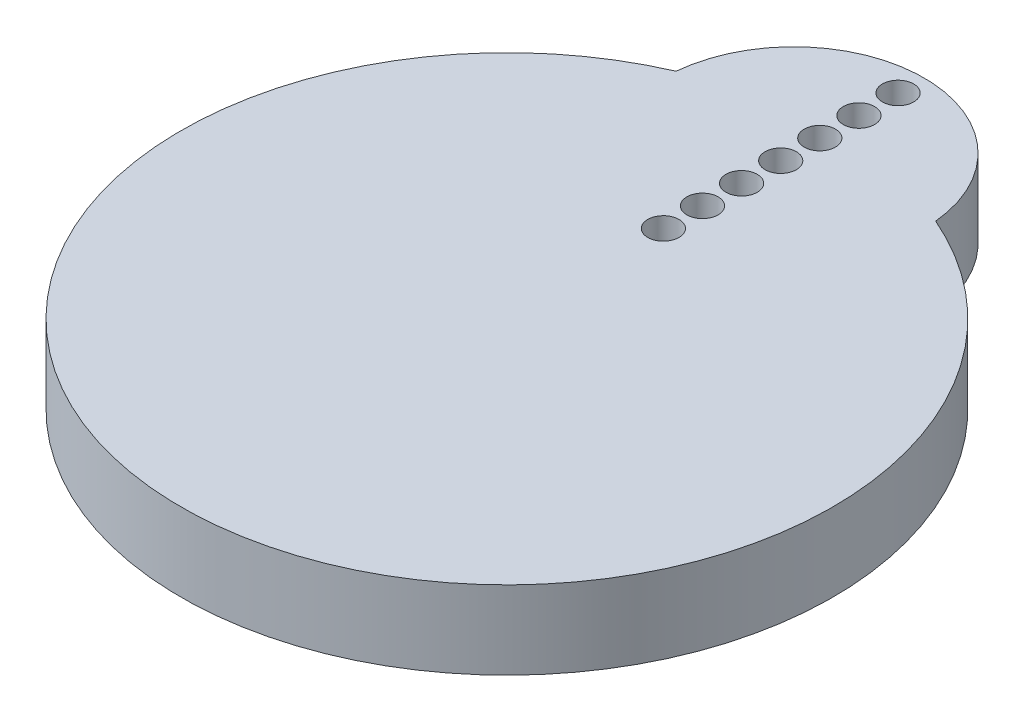
from build123d import *

# Parameters (mm, degrees)
SKETCH1_R           = 12.5
BOSS_EXTRUDE1_DEPTH = 3
SKETCH3_R           = 5
BOSS_EXTRUDE2_DEPTH = 3
CUT_EXTRUDE1_DEPTH  = 10


with BuildPart() as part:
    # Sketch1 → Boss-Extrude1 (new body)
    with BuildSketch(Plane(origin=(0, 0, 0), x_dir=(1, 0, 0), z_dir=(0, 1, 0))):
        Circle(SKETCH1_R)
    extrude(amount=BOSS_EXTRUDE1_DEPTH)

    # Sketch3 → Boss-Extrude2 (add)
    with BuildSketch(Plane(origin=(0, 3, 0), x_dir=(1, 0, 0), z_dir=(0, 1, 0))):
        with Locations((0, 11)):
            Circle(SKETCH3_R)
    extrude(amount=-BOSS_EXTRUDE2_DEPTH)

    # Sketch4 → Cut-Extrude1 (cut)
    with BuildSketch(Plane(origin=(0, 3, 0), x_dir=(1, 0, 0), z_dir=(0, 1, 0))):
        with BuildLine():
            ThreePointArc((0.6, 6), (0.424264069, 6.424264069), (0, 6.6))
            Line((0, 6.6), (0, 5.4))
            ThreePointArc((0, 5.4), (0.424264069, 5.575735931), (0.6, 6))
        make_face()
        with BuildLine():
            Line((0, 5.4), (0, 6.6))
            ThreePointArc((0, 6.6), (-0.6, 6), (0, 5.4))
        make_face()
        with BuildLine():
            ThreePointArc((0.6, 7.5), (0.424264069, 7.924264069), (0, 8.1))
            Line((0, 8.1), (0, 6.9))
            ThreePointArc((0, 6.9), (0.424264069, 7.075735931), (0.6, 7.5))
        make_face()
        with BuildLine():
            Line((0, 6.9), (0, 8.1))
            ThreePointArc((0, 8.1), (-0.6, 7.5), (0, 6.9))
        make_face()
        with BuildLine():
            ThreePointArc((0.6, 9), (0.424264069, 9.424264069), (0, 9.6))
            Line((0, 9.6), (0, 8.4))
            ThreePointArc((0, 8.4), (0.424264069, 8.575735931), (0.6, 9))
        make_face()
        with BuildLine():
            Line((0, 8.4), (0, 9.6))
            ThreePointArc((0, 9.6), (-0.6, 9), (0, 8.4))
        make_face()
        with BuildLine():
            ThreePointArc((0.6, 10.5), (0.424264069, 10.924264069), (0, 11.1))
            Line((0, 11.1), (0, 9.9))
            ThreePointArc((0, 9.9), (0.424264069, 10.075735931), (0.6, 10.5))
        make_face()
        with BuildLine():
            Line((0, 9.9), (0, 11.1))
            ThreePointArc((0, 11.1), (-0.6, 10.5), (0, 9.9))
        make_face()
        with BuildLine():
            ThreePointArc((0.6, 12), (0.424264069, 12.424264069), (0, 12.6))
            Line((0, 12.6), (0, 11.4))
            ThreePointArc((0, 11.4), (0.424264069, 11.575735931), (0.6, 12))
        make_face()
        with BuildLine():
            Line((0, 11.4), (0, 12.6))
            ThreePointArc((0, 12.6), (-0.6, 12), (0, 11.4))
        make_face()
        with BuildLine():
            ThreePointArc((0.6, 13.5), (0.424264069, 13.924264069), (0, 14.1))
            Line((0, 14.1), (0, 12.9))
            ThreePointArc((0, 12.9), (0.424264069, 13.075735931), (0.6, 13.5))
        make_face()
        with BuildLine():
            Line((0, 12.9), (0, 14.1))
            ThreePointArc((0, 14.1), (-0.6, 13.5), (0, 12.9))
        make_face()
        with BuildLine():
            ThreePointArc((0.6, 15), (0.424264069, 15.424264069), (0, 15.6))
            Line((0, 15.6), (0, 14.4))
            ThreePointArc((0, 14.4), (0.424264069, 14.575735931), (0.6, 15))
        make_face()
        with BuildLine():
            Line((0, 14.4), (0, 15.6))
            ThreePointArc((0, 15.6), (-0.6, 15), (0, 14.4))
        make_face()
    extrude(amount=-CUT_EXTRUDE1_DEPTH, mode=Mode.SUBTRACT)


solid = part.part
